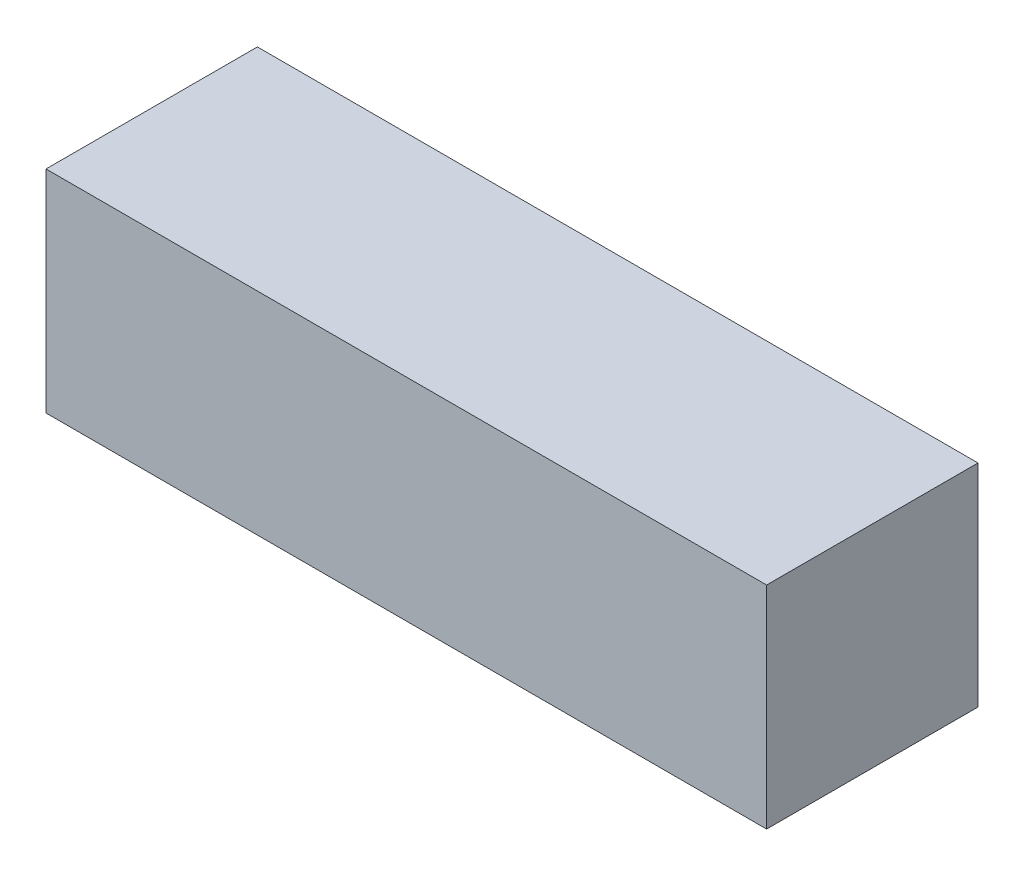
from build123d import *

# Parameters (mm, degrees)
SKETCH1_W           = 38.1
SKETCH1_H           = 11.176
BOSS_EXTRUDE1_DEPTH = 11.176
SHELL1_T            = -2.286


with BuildPart() as part:
    # Sketch1 → Boss-Extrude1 (new body)
    with BuildSketch(Plane(origin=(0, 0, 0), x_dir=(1, 0, 0), z_dir=(0, 1, 0))):
        with Locations((19.05, 5.588)):
            Rectangle(SKETCH1_W, SKETCH1_H)
    extrude(amount=BOSS_EXTRUDE1_DEPTH)

    # Shell1
    shell1_openings = [part.faces().sort_by_distance(p)[0] for p in [
        (19.05, 0, -5.588),
    ]]
    offset(amount=SHELL1_T, openings=shell1_openings, kind=Kind.INTERSECTION)


solid = part.part
